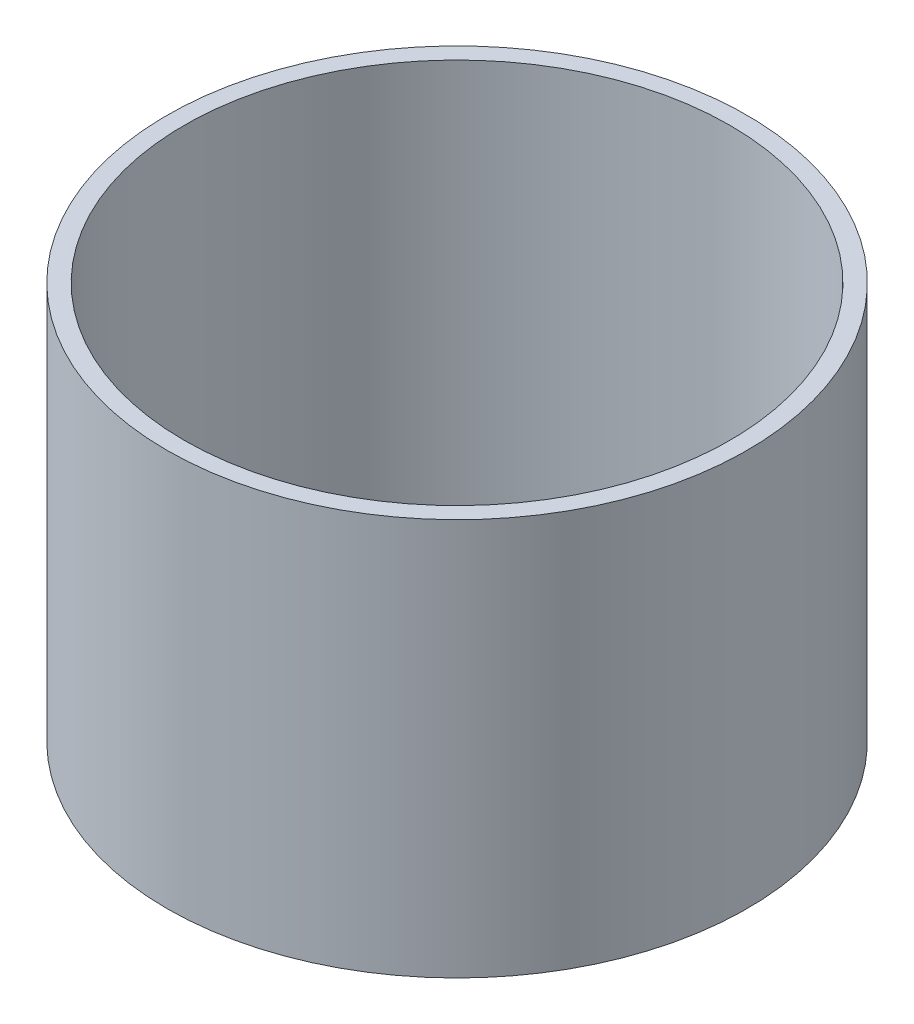
from build123d import *

# Parameters (mm, degrees)
SKETCH7_R           = 29.239508
SKETCH7_R_2         = 27.5
BOSS_EXTRUDE1_DEPTH = 40


with BuildPart() as part:
    # Sketch7 → Boss-Extrude1 (new body)
    with BuildSketch(Plane(origin=(0, 0, 0), x_dir=(1, 0, 0), z_dir=(0, 1, 0))):
        Circle(SKETCH7_R)
        Circle(SKETCH7_R_2, mode=Mode.SUBTRACT)
    extrude(amount=-BOSS_EXTRUDE1_DEPTH)


solid = part.part
